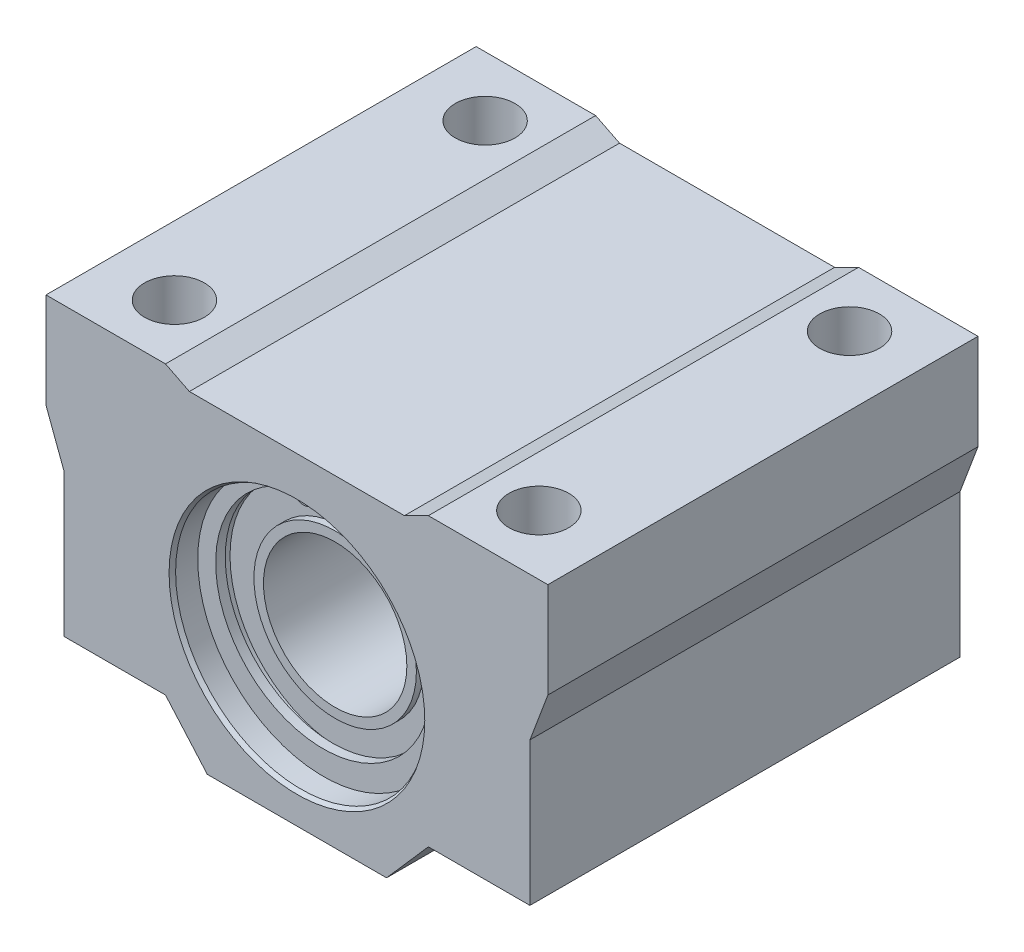
from build123d import *

# Parameters (mm, degrees)
SKETCH1_R                  = 10.5
BOSS_EXTRUDE1_DEPTH        = 18
SKETCH3_R                  = 0.487346303
BOSS_EXTRUDE2_DEPTH        = 0.8
M5_TAPPED_HOLE1_AT_2_COUNT = 2
M5_TAPPED_HOLE1_AT_2_PITCH = 26
M5_TAPPED_HOLE1_AT_3_COUNT = 2
M5_TAPPED_HOLE1_AT_3_PITCH = 30.5
M5_TAPPED_HOLE1_AT_4_COUNT = 2
M5_TAPPED_HOLE1_AT_4_PITCH = 40.078048855
CHAMFER1_SIZE              = 0.2
CHAMFER1_SIZE2             = 0.346410162
CHAMFER1_PART_2_SIZE       = 0.2
CHAMFER1_PART_2_SIZE2      = 0.346410162


with BuildPart() as part:
    # Sketch1 → Boss-Extrude1 (new body, symmetric)
    with BuildSketch(Plane.XY):
        Polygon((-9, -1), (9, -1), (11, 0), (21, 0), (21, -8), (19.5, -12), (19.5, -24), (11, -24), (7.5, -28), (-7.5, -28), (-11, -24), (-19.5, -24), (-19.5, -12), (-21, -8), (-21, 0), (-11, 0), align=None)
        with Locations((0, -15)):
            Circle(SKETCH1_R, mode=Mode.SUBTRACT)
    extrude(amount=BOSS_EXTRUDE1_DEPTH, both=True)

    # Sketch2 → Revolve1 (revolve)
    with BuildSketch(Plane(origin=(0, 0, 0), x_dir=(0, 0, -1), z_dir=(1, 0, 0))):
        Polygon((-15, -4.5), (15, -4.5), (15, -5.6), (14.2, -5.6), (14.2, -8.2), (14.8, -8.2), (14.8, -9), (-14.8, -9), (-14.8, -8.2), (-14.2, -8.2), (-14.2, -5.6), (-15, -5.6), align=None)
    revolve(axis=Axis((0, -15, 30.2753079), (0, 0, -1)))

    # Sketch3 → Boss-Extrude2 (add)
    with BuildSketch(Plane.XY.offset(15)):
        with BuildLine():
            Line((1.141194716, -4.059356755), (0.782998979, -5.534631753))
            ThreePointArc((0.782998979, -5.534631753), (1.493962208, -6.63757679), (2.559436926, -5.871600228))
            ThreePointArc((2.559436926, -5.871600228), (0, -23.5), (-2.559436926, -5.871600228))
            ThreePointArc((-2.559436926, -5.871600228), (-1.493962208, -6.63757679), (-0.782998979, -5.534631753))
            Line((-0.782998979, -5.534631753), (-1.141194716, -4.059356755))
            ThreePointArc((-1.141194716, -4.059356755), (0, -26), (1.141194716, -4.059356755))
        make_face()
        with Locations((1.662663475, -5.748213677)):
            Circle(SKETCH3_R, mode=Mode.SUBTRACT)
        with Locations((-1.662663475, -5.748213677)):
            Circle(SKETCH3_R, mode=Mode.SUBTRACT)
    boss_extrude2 = extrude(amount=BOSS_EXTRUDE2_DEPTH)

    # Mirror1: Boss-Extrude2 across plane
    add(boss_extrude2.mirror(Plane.XY))

    # Sketch6 → M5 Tapped Hole1 (revolve, cut)
    with BuildSketch(Plane(origin=(15.25, 0, -13), x_dir=(0, 0, 1), z_dir=(1, 0, 0))):
        Polygon((0, 0), (0, 24), (2.5, 24), (2.1, 23.6), (2.1, 12), (2.5, 12), (2.5, 0), align=None)
    m5_tapped_hole1 = revolve(axis=Axis((15.25, 6.35, -13), (0, -1, 0)), mode=Mode.SUBTRACT)

    # M5 Tapped Hole1 at 2: M5 Tapped Hole1 ×2
    with Locations(*[(0, 0, i * M5_TAPPED_HOLE1_AT_2_PITCH) for i in range(1, M5_TAPPED_HOLE1_AT_2_COUNT)]):
        add(m5_tapped_hole1, mode=Mode.SUBTRACT)

    # M5 Tapped Hole1 at 3: M5 Tapped Hole1 ×2
    with Locations(*[(-i * M5_TAPPED_HOLE1_AT_3_PITCH, 0, 0) for i in range(1, M5_TAPPED_HOLE1_AT_3_COUNT)]):
        add(m5_tapped_hole1, mode=Mode.SUBTRACT)

    # M5 Tapped Hole1 at 4: M5 Tapped Hole1 ×2
    with Locations(*[Vector(-0.761015091, 0, 0.648734176) * (i * M5_TAPPED_HOLE1_AT_4_PITCH) for i in range(1, M5_TAPPED_HOLE1_AT_4_COUNT)]):
        add(m5_tapped_hole1, mode=Mode.SUBTRACT)

    # Chamfer1
    chamfer1_edges = [part.edges().sort_by_distance(p)[0] for p in [
        (-10.5, -15, -18),
    ]]
    chamfer1_side = [part.faces().sort_by_distance(p)[0] for p in [
        (-10.5, -15, -16.5),
    ]]
    chamfer(chamfer1_edges, length=CHAMFER1_SIZE, length2=CHAMFER1_SIZE2, reference=chamfer1_side[0])

    # Chamfer1 part 2
    chamfer1_part_2_edges = [part.edges().sort_by_distance(p)[0] for p in [
        (-10.5, -15, 18),
    ]]
    chamfer1_part_2_side = [part.faces().sort_by_distance(p)[0] for p in [
        (0, -1.504777179, 18),
    ]]
    chamfer(chamfer1_part_2_edges, length=CHAMFER1_PART_2_SIZE, length2=CHAMFER1_PART_2_SIZE2, reference=chamfer1_part_2_side[0])


solid = part.part
